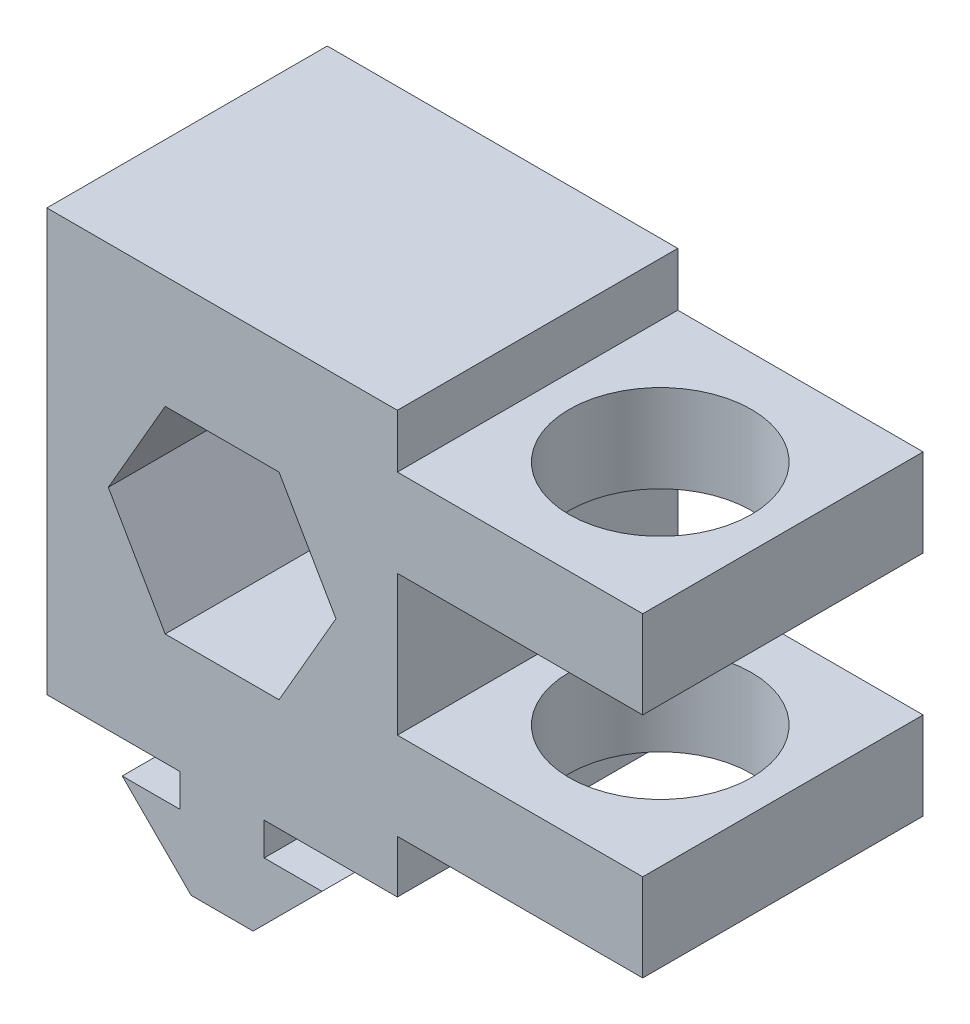
from build123d import *

# Parameters (mm, degrees)
BOSS_EXTRUDE1_DEPTH = 10.16
SKETCH2_R           = 6.604
CUT_EXTRUDE1_DEPTH  = 38.916561489


with BuildPart() as part:
    # Sketch1 → Boss-Extrude1 (new body, symmetric)
    with BuildSketch(Plane.XY):
        Polygon((2.24536, 0), (-2.24536, 0), (-7.239, 4.99364), (-3.048, 4.99364), (-3.048, 7.366), (-12.7, 7.366), (-12.7, 37.916561489), (12.7, 37.916561489), (12.7, 34.036), (30.48, 34.036), (30.48, 27.686), (12.7, 27.686), (12.7, 17.526), (30.48, 17.526), (30.48, 11.176), (12.7, 11.176), (12.7, 7.366), (3.048, 7.366), (3.048, 4.99364), (7.239, 4.99364), align=None)
        Polygon((-4.124445986, 29.74975), (-8.248891971, 22.606), (-4.124445986, 15.46225), (4.124445986, 15.46225), (8.248891971, 22.606), (4.124445986, 29.74975), align=None, mode=Mode.SUBTRACT)
    extrude(amount=BOSS_EXTRUDE1_DEPTH, both=True)

    # Sketch2 → Cut-Extrude1 (cut, through all)
    with BuildSketch(Plane(origin=(0, 37.916561489, 0), x_dir=(1, 0, 0), z_dir=(0, 1, 0))):
        with Locations((21.59, 0)):
            Circle(SKETCH2_R)
    extrude(amount=-CUT_EXTRUDE1_DEPTH, mode=Mode.SUBTRACT)


solid = part.part
